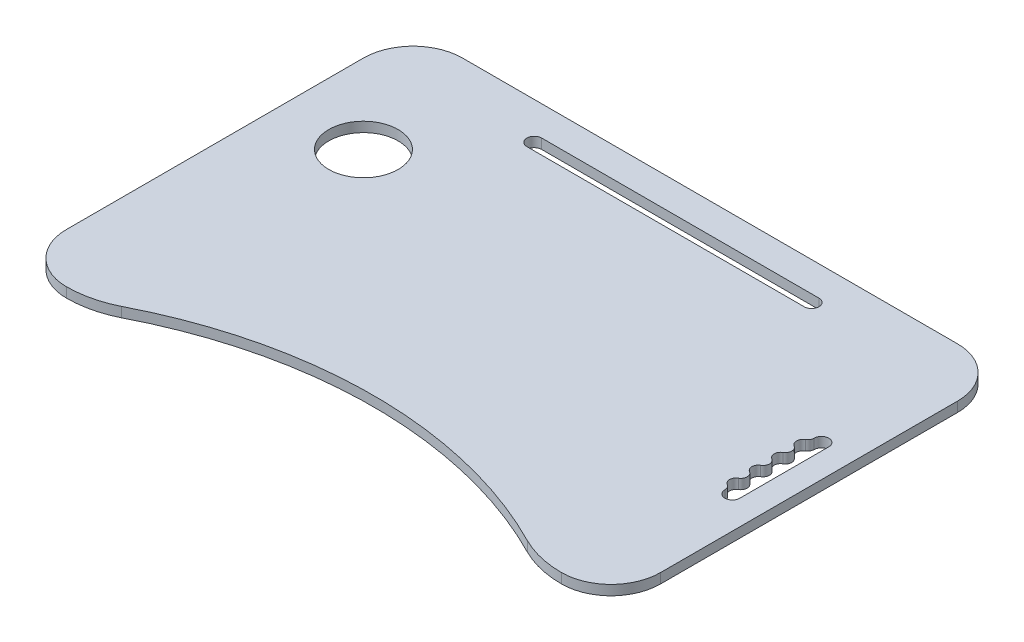
from build123d import *

# Parameters (mm, degrees)
SKETCH1_R               = 35
BOSS_EXTRUDE2_DEPTH     = 5
SKETCH3_W               = 200
SKETCH3_H               = 15
BOSS_EXTRUDE3_DEPTH     = 10
SKETCH5_W               = 200
SKETCH5_H               = 4
CUT_EXTRUDE1_DEPTH      = 5
FILLET1_R               = 2
BOSS_EXTRUDE4_DEPTH     = 8
FILLET2_R               = 1
CUT_EXTRUDE2_DEPTH      = 126
CUT_EXTRUDE2_DEPTH_BACK = 476
SKETCH9_R               = 1.5
CUT_EXTRUDE3_DEPTH      = 5


with BuildPart() as part:
    # Sketch1 → Boss-Extrude2 (new body, symmetric)
    with BuildSketch(Plane(origin=(0, 0, 0), x_dir=(1, 0, 0), z_dir=(0, 1, 0))):
        with BuildLine():
            Line((-300, 150), (-300, -150))
            ThreePointArc((-300, -150), (-285.355339059, -185.355339059), (-250, -200))
            ThreePointArc((-250, -200), (-226.897361562, -197.318952424), (-205.022721068, -189.418318135))
            ThreePointArc((-205.022721068, -189.418318135), (0, -140), (205.022721068, -189.418318135))
            ThreePointArc((205.022721068, -189.418318135), (226.897361562, -197.318952424), (250, -200))
            ThreePointArc((250, -200), (285.355339059, -185.355339059), (300, -150))
            Line((300, -150), (300, 150))
            ThreePointArc((300, 150), (285.355339059, 185.355339059), (250, 200))
            Line((250, 200), (-250, 200))
            ThreePointArc((-250, 200), (-285.355339059, 185.355339059), (-300, 150))
        make_face()
        with Locations((-220, 70)):
            Circle(SKETCH1_R, mode=Mode.SUBTRACT)
        with BuildLine():
            Line((140, 170), (-140, 170))
            ThreePointArc((-140, 170), (-147.5, 162.5), (-140, 155))
            Line((-140, 155), (140, 155))
            ThreePointArc((140, 155), (147.5, 162.5), (140, 170))
        make_face(mode=Mode.SUBTRACT)
        with BuildLine():
            Line((275, -45), (275, 45))
            ThreePointArc((275, 45), (267.5, 52.5), (260, 45))
            ThreePointArc((260, 45), (259.130057614, 41.755411156), (256.753609774, 39.381247686))
            ThreePointArc((256.753609774, 39.381247686), (253.5, 33.75), (256.753609774, 28.118752314))
            ThreePointArc((256.753609774, 28.118752314), (260, 22.5), (256.753609774, 16.881247686))
            ThreePointArc((256.753609774, 16.881247686), (253.5, 11.25), (256.753609774, 5.618752314))
            ThreePointArc((256.753609774, 5.618752314), (260, 0), (256.753609774, -5.618752314))
            ThreePointArc((256.753609774, -5.618752314), (253.5, -11.25), (256.753609774, -16.881247686))
            ThreePointArc((256.753609774, -16.881247686), (260, -22.5), (256.753609774, -28.118752314))
            ThreePointArc((256.753609774, -28.118752314), (253.5, -33.75), (256.753609774, -39.381247686))
            ThreePointArc((256.753609774, -39.381247686), (259.130057614, -41.755411156), (260, -45))
            ThreePointArc((260, -45), (267.5, -52.5), (275, -45))
        make_face(mode=Mode.SUBTRACT)
    extrude(amount=BOSS_EXTRUDE2_DEPTH, both=True)

    # Sketch3 → Boss-Extrude3 (add)
    with BuildSketch(Plane(origin=(0, -5, 0), x_dir=(-1, 0, 0), z_dir=(0, -1, 0))):
        with Locations((-180, -77.5)):
            Rectangle(SKETCH3_W, SKETCH3_H)
        with Locations((-180, 77.5)):
            Rectangle(SKETCH3_W, SKETCH3_H)
    extrude(amount=BOSS_EXTRUDE3_DEPTH)

    # Sketch5 → Cut-Extrude1 (cut)
    with BuildSketch(Plane(origin=(0, 0, 70), x_dir=(-1, 0, 0), z_dir=(0, 0, -1))):
        with Locations((-180, -10)):
            Rectangle(SKETCH5_W, SKETCH5_H)
    cut_extrude1 = extrude(amount=-CUT_EXTRUDE1_DEPTH, mode=Mode.SUBTRACT)

    # Mirror1: Cut-Extrude1 across plane
    add(cut_extrude1.mirror(Plane.XY), mode=Mode.SUBTRACT)

    # Fillet1
    fillet1_edges = [part.edges().sort_by_distance(p)[0] for p in [
        (180, -5, -85),
        (80, -10, -85),
        (280, -5, -77.5),
        (280, -10, -85),
        (80, -5, -77.5),
        (180, -15, -85),
        (280, -15, -77.5),
        (80, -15, -77.5),
        (280, -5, 77.5),
        (180, -5, 85),
        (280, -10, 85),
        (80, -5, 77.5),
        (80, -10, 85),
        (280, -15, 77.5),
        (180, -15, 85),
        (80, -15, 77.5),
    ]]
    fillet(fillet1_edges, radius=FILLET1_R)

    # Sketch6 → Boss-Extrude4 (add)
    with BuildSketch(Plane.XZ.offset(5)):
        with BuildLine():
            Line((215, -125), (215, -135))
            ThreePointArc((215, -135), (210, -140), (205, -135))
            Line((205, -135), (205, -125))
            ThreePointArc((205, -125), (210, -120), (215, -125))
        make_face()
        with BuildLine():
            Line((120, -125), (120, -135))
            ThreePointArc((120, -135), (115, -140), (110, -135))
            Line((110, -135), (110, -125))
            ThreePointArc((110, -125), (115, -120), (120, -125))
        make_face()
        with BuildLine():
            Line((25, -125), (25, -135))
            ThreePointArc((25, -135), (20, -140), (15, -135))
            Line((15, -135), (15, -125))
            ThreePointArc((15, -125), (20, -120), (25, -125))
        make_face()
        with BuildLine():
            Line((-70, -125), (-70, -135))
            ThreePointArc((-70, -135), (-75, -140), (-80, -135))
            Line((-80, -135), (-80, -125))
            ThreePointArc((-80, -125), (-75, -120), (-70, -125))
        make_face()
        with BuildLine():
            Line((-165, -125), (-165, -135))
            ThreePointArc((-165, -135), (-170, -140), (-175, -135))
            Line((-175, -135), (-175, -125))
            ThreePointArc((-175, -125), (-170, -120), (-165, -125))
        make_face()
    extrude(amount=BOSS_EXTRUDE4_DEPTH)

    # Fillet2
    fillet2_edges = [part.edges().sort_by_distance(p)[0] for p in [
        (210, -5, -120),
        (205, -5, -130),
        (210, -5, -140),
        (215, -5, -130),
        (210, -13, -120),
        (205, -13, -130),
        (210, -13, -140),
        (215, -13, -130),
        (115, -5, -120),
        (110, -5, -130),
        (115, -5, -140),
        (120, -5, -130),
        (115, -13, -120),
        (110, -13, -130),
        (115, -13, -140),
        (120, -13, -130),
        (20, -5, -120),
        (15, -5, -130),
        (20, -5, -140),
        (25, -5, -130),
        (20, -13, -120),
        (15, -13, -130),
        (20, -13, -140),
        (25, -13, -130),
        (-75, -5, -120),
        (-80, -5, -130),
        (-75, -5, -140),
        (-70, -5, -130),
        (-75, -13, -120),
        (-80, -13, -130),
        (-75, -13, -140),
        (-70, -13, -130),
        (-170, -5, -120),
        (-175, -5, -130),
        (-170, -5, -140),
        (-165, -5, -130),
        (-170, -13, -120),
        (-175, -13, -130),
        (-170, -13, -140),
        (-165, -13, -130),
    ]]
    fillet(fillet2_edges, radius=FILLET2_R)

    # Sketch8 → Cut-Extrude2 (cut, two sides)
    with BuildSketch(Plane.ZY.offset(175)) as cut_extrude2_sk:
        with BuildLine():
            Line((-131.25, -11.165063509), (-131.25, -13))
            Line((-131.25, -13), (-128.75, -13))
            Line((-128.75, -13), (-128.75, -11.165063509))
            ThreePointArc((-128.75, -11.165063509), (-130, -6.5), (-131.25, -11.165063509))
        make_face()
    extrude(amount=CUT_EXTRUDE2_DEPTH, mode=Mode.SUBTRACT)
    extrude(cut_extrude2_sk.sketch, amount=-CUT_EXTRUDE2_DEPTH_BACK, mode=Mode.SUBTRACT)

    # Sketch9 → Cut-Extrude3 (cut)
    with BuildSketch(Plane.XZ.offset(5)):
        with Locations((-230, 124)):
            Circle(SKETCH9_R)
        with Locations((-270, 124)):
            Circle(SKETCH9_R)
        with Locations((-230, -156)):
            Circle(SKETCH9_R)
        with Locations((-270, -156)):
            Circle(SKETCH9_R)
        with Locations((-270, -124)):
            Circle(SKETCH9_R)
        with Locations((-230, -124)):
            Circle(SKETCH9_R)
        with Locations((-270, 156)):
            Circle(SKETCH9_R)
        with Locations((-230, 156)):
            Circle(SKETCH9_R)
        with Locations((230, 156)):
            Circle(SKETCH9_R)
        with Locations((270, 156)):
            Circle(SKETCH9_R)
        with Locations((270, 124)):
            Circle(SKETCH9_R)
        with Locations((230, 124)):
            Circle(SKETCH9_R)
        with Locations((230, -124)):
            Circle(SKETCH9_R)
        with Locations((270, -124)):
            Circle(SKETCH9_R)
        with Locations((270, -156)):
            Circle(SKETCH9_R)
        with Locations((230, -156)):
            Circle(SKETCH9_R)
    extrude(amount=-CUT_EXTRUDE3_DEPTH, mode=Mode.SUBTRACT)


solid = part.part
